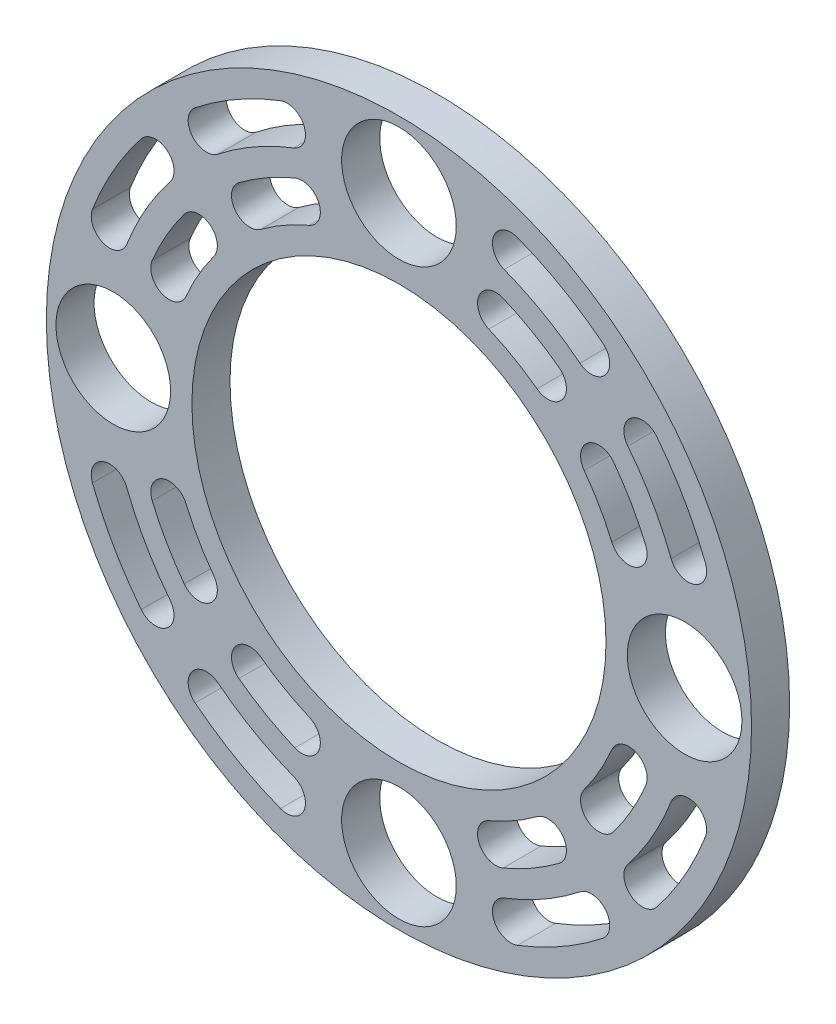
from build123d import *

# Parameters (mm, degrees)
SKETCH6_R           = 58.75
SKETCH6_R_2         = 34.5
BOSS_EXTRUDE1_DEPTH = 6.35
SKETCH5_R           = 9.55
CUT_EXTRUDE1_DEPTH  = 7.35
CUT_EXTRUDE3_DEPTH  = 7.35


with BuildPart() as part:
    # Sketch6 → Boss-Extrude1 (new body)
    with BuildSketch(Plane.XY):
        Circle(SKETCH6_R)
        Circle(SKETCH6_R_2, mode=Mode.SUBTRACT)
    extrude(amount=BOSS_EXTRUDE1_DEPTH)

    # Sketch5 → Cut-Extrude1 (cut, through all)
    with BuildSketch(Plane.XY):
        with Locations((0, 47.6)):
            Circle(SKETCH5_R)
        with Locations((47.6, 0)):
            Circle(SKETCH5_R)
        with Locations((0, -47.6)):
            Circle(SKETCH5_R)
        with Locations((-47.6, 0)):
            Circle(SKETCH5_R)
    extrude(amount=CUT_EXTRUDE1_DEPTH, mode=Mode.SUBTRACT)

    # Sketch9 → Cut-Extrude3 (cut, through all)
    with BuildSketch(Plane.XY):
        with BuildLine():
            ThreePointArc((33.958355337, 42.946392198), (27.156576229, 47.540328854), (19.744469053, 51.065824597))
            ThreePointArc((19.744469053, 51.065824597), (15.783619294, 49.313830965), (17.535612926, 45.352981206))
            ThreePointArc((17.535612926, 45.352981206), (24.118511765, 42.221890237), (30.159361247, 38.141887135))
            ThreePointArc((30.159361247, 38.141887135), (34.461110824, 38.644642621), (33.958355337, 42.946392198))
        make_face()
        with BuildLine():
            ThreePointArc((51.065824597, 19.744469053), (47.540328854, 27.156576229), (42.946392198, 33.958355337))
            ThreePointArc((42.946392198, 33.958355337), (38.644642621, 34.461110824), (38.141887135, 30.159361247))
            ThreePointArc((38.141887135, 30.159361247), (42.221890237, 24.118511765), (45.352981206, 17.535612926))
            ThreePointArc((45.352981206, 17.535612926), (49.313830965, 15.783619294), (51.065824597, 19.744469053))
        make_face()
        with BuildLine():
            ThreePointArc((26.668852196, 35.779364829), (22.171350506, 38.72753338), (17.351873742, 41.113295935))
            ThreePointArc((17.351873742, 41.113295935), (13.339558176, 39.482610098), (14.970244012, 35.470294532))
            ThreePointArc((14.970244012, 35.470294532), (19.128223966, 33.411989583), (23.008421502, 30.868471617))
            ThreePointArc((23.008421502, 30.868471617), (27.294083455, 31.493702876), (26.668852196, 35.779364829))
        make_face()
        with BuildLine():
            ThreePointArc((41.113295935, 17.351873742), (38.72753338, 22.171350506), (35.779364829, 26.668852196))
            ThreePointArc((35.779364829, 26.668852196), (31.493702876, 27.294083455), (30.868471617, 23.008421502))
            ThreePointArc((30.868471617, 23.008421502), (33.411989583, 19.128223966), (35.470294532, 14.970244012))
            ThreePointArc((35.470294532, 14.970244012), (39.482610098, 13.339558176), (41.113295935, 17.351873742))
        make_face()
        with BuildLine():
            ThreePointArc((-33.958355337, 42.946392198), (-27.156576229, 47.540328854), (-19.744469053, 51.065824597))
            ThreePointArc((-19.744469053, 51.065824597), (-15.783619294, 49.313830965), (-17.535612926, 45.352981206))
            ThreePointArc((-17.535612926, 45.352981206), (-24.118511765, 42.221890237), (-30.159361247, 38.141887135))
            ThreePointArc((-30.159361247, 38.141887135), (-34.461110824, 38.644642621), (-33.958355337, 42.946392198))
        make_face()
        with BuildLine():
            ThreePointArc((-51.065824597, 19.744469053), (-47.540328854, 27.156576229), (-42.946392198, 33.958355337))
            ThreePointArc((-42.946392198, 33.958355337), (-38.644642621, 34.461110824), (-38.141887135, 30.159361247))
            ThreePointArc((-38.141887135, 30.159361247), (-42.221890237, 24.118511765), (-45.352981206, 17.535612926))
            ThreePointArc((-45.352981206, 17.535612926), (-49.313830965, 15.783619294), (-51.065824597, 19.744469053))
        make_face()
        with BuildLine():
            ThreePointArc((-26.668852196, 35.779364829), (-22.171350506, 38.72753338), (-17.351873742, 41.113295935))
            ThreePointArc((-17.351873742, 41.113295935), (-13.339558176, 39.482610098), (-14.970244012, 35.470294532))
            ThreePointArc((-14.970244012, 35.470294532), (-19.128223966, 33.411989583), (-23.008421502, 30.868471617))
            ThreePointArc((-23.008421502, 30.868471617), (-27.294083455, 31.493702876), (-26.668852196, 35.779364829))
        make_face()
        with BuildLine():
            ThreePointArc((-41.113295935, 17.351873742), (-38.72753338, 22.171350506), (-35.779364829, 26.668852196))
            ThreePointArc((-35.779364829, 26.668852196), (-31.493702876, 27.294083455), (-30.868471617, 23.008421502))
            ThreePointArc((-30.868471617, 23.008421502), (-33.411989583, 19.128223966), (-35.470294532, 14.970244012))
            ThreePointArc((-35.470294532, 14.970244012), (-39.482610098, 13.339558176), (-41.113295935, 17.351873742))
        make_face()
        with BuildLine():
            ThreePointArc((-33.958355337, -42.946392198), (-27.156576229, -47.540328854), (-19.744469053, -51.065824597))
            ThreePointArc((-19.744469053, -51.065824597), (-15.783619294, -49.313830965), (-17.535612926, -45.352981206))
            ThreePointArc((-17.535612926, -45.352981206), (-24.118511765, -42.221890237), (-30.159361247, -38.141887135))
            ThreePointArc((-30.159361247, -38.141887135), (-34.461110824, -38.644642621), (-33.958355337, -42.946392198))
        make_face()
        with BuildLine():
            ThreePointArc((-51.065824597, -19.744469053), (-47.540328854, -27.156576229), (-42.946392198, -33.958355337))
            ThreePointArc((-42.946392198, -33.958355337), (-38.644642621, -34.461110824), (-38.141887135, -30.159361247))
            ThreePointArc((-38.141887135, -30.159361247), (-42.221890237, -24.118511765), (-45.352981206, -17.535612926))
            ThreePointArc((-45.352981206, -17.535612926), (-49.313830965, -15.783619294), (-51.065824597, -19.744469053))
        make_face()
        with BuildLine():
            ThreePointArc((-26.668852196, -35.779364829), (-22.171350506, -38.72753338), (-17.351873742, -41.113295935))
            ThreePointArc((-17.351873742, -41.113295935), (-13.339558176, -39.482610098), (-14.970244012, -35.470294532))
            ThreePointArc((-14.970244012, -35.470294532), (-19.128223966, -33.411989583), (-23.008421502, -30.868471617))
            ThreePointArc((-23.008421502, -30.868471617), (-27.294083455, -31.493702876), (-26.668852196, -35.779364829))
        make_face()
        with BuildLine():
            ThreePointArc((-41.113295935, -17.351873742), (-38.72753338, -22.171350506), (-35.779364829, -26.668852196))
            ThreePointArc((-35.779364829, -26.668852196), (-31.493702876, -27.294083455), (-30.868471617, -23.008421502))
            ThreePointArc((-30.868471617, -23.008421502), (-33.411989583, -19.128223966), (-35.470294532, -14.970244012))
            ThreePointArc((-35.470294532, -14.970244012), (-39.482610098, -13.339558176), (-41.113295935, -17.351873742))
        make_face()
        with BuildLine():
            ThreePointArc((33.958355337, -42.946392198), (27.156576229, -47.540328854), (19.744469053, -51.065824597))
            ThreePointArc((19.744469053, -51.065824597), (15.783619294, -49.313830965), (17.535612926, -45.352981206))
            ThreePointArc((17.535612926, -45.352981206), (24.118511765, -42.221890237), (30.159361247, -38.141887135))
            ThreePointArc((30.159361247, -38.141887135), (34.461110824, -38.644642621), (33.958355337, -42.946392198))
        make_face()
        with BuildLine():
            ThreePointArc((26.668852196, -35.779364829), (22.171350506, -38.72753338), (17.351873742, -41.113295935))
            ThreePointArc((17.351873742, -41.113295935), (13.339558176, -39.482610098), (14.970244012, -35.470294532))
            ThreePointArc((14.970244012, -35.470294532), (19.128223966, -33.411989583), (23.008421502, -30.868471617))
            ThreePointArc((23.008421502, -30.868471617), (27.294083455, -31.493702876), (26.668852196, -35.779364829))
        make_face()
        with BuildLine():
            ThreePointArc((41.113295935, -17.351873742), (38.72753338, -22.171350506), (35.779364829, -26.668852196))
            ThreePointArc((35.779364829, -26.668852196), (31.493702876, -27.294083455), (30.868471617, -23.008421502))
            ThreePointArc((30.868471617, -23.008421502), (33.411989583, -19.128223966), (35.470294532, -14.970244012))
            ThreePointArc((35.470294532, -14.970244012), (39.482610098, -13.339558176), (41.113295935, -17.351873742))
        make_face()
        with BuildLine():
            ThreePointArc((51.065824597, -19.744469053), (47.540328854, -27.156576229), (42.946392198, -33.958355337))
            ThreePointArc((42.946392198, -33.958355337), (38.644642621, -34.461110824), (38.141887135, -30.159361247))
            ThreePointArc((38.141887135, -30.159361247), (42.221890237, -24.118511765), (45.352981206, -17.535612926))
            ThreePointArc((45.352981206, -17.535612926), (49.313830965, -15.783619294), (51.065824597, -19.744469053))
        make_face()
    extrude(amount=CUT_EXTRUDE3_DEPTH, mode=Mode.SUBTRACT)


solid = part.part
